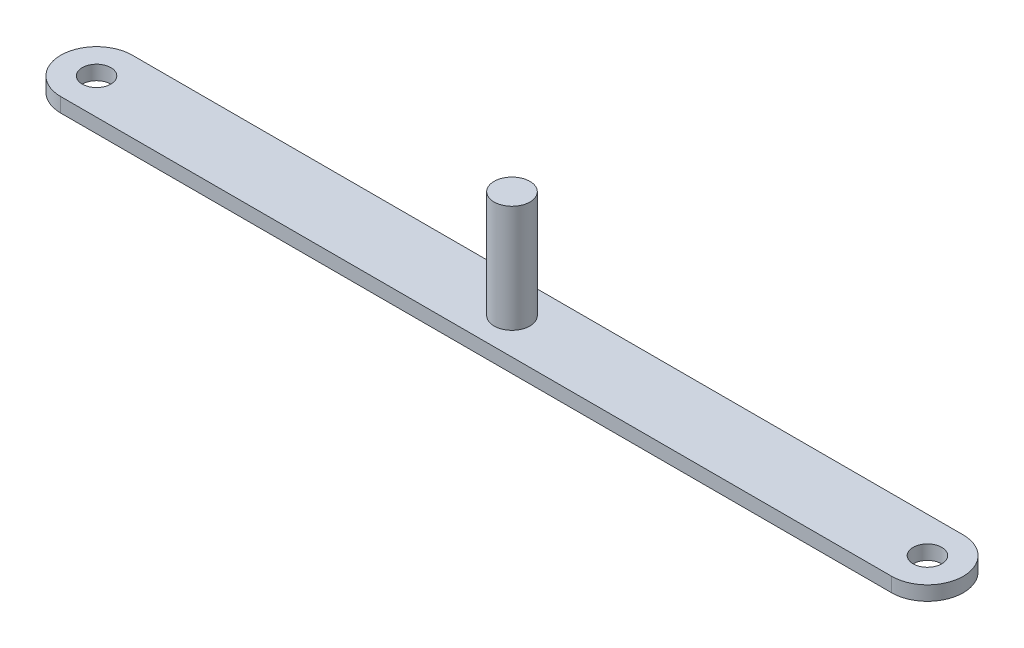
from build123d import *

# Parameters (mm, degrees)
SKETCH1_R           = 2
BOSS_EXTRUDE1_DEPTH = 2
SKETCH2_R           = 2.5
BOSS_EXTRUDE2_DEPTH = 15


with BuildPart() as part:
    # Sketch1 → Boss-Extrude1 (new body)
    with BuildSketch(Plane(origin=(0, 0, 0), x_dir=(1, 0, 0), z_dir=(0, 1, 0))):
        with BuildLine():
            Line((-58, 5), (58, 5))
            ThreePointArc((58, 5), (63, 0), (58, -5))
            Line((58, -5), (-58, -5))
            ThreePointArc((-58, -5), (-63, 0), (-58, 5))
        make_face()
        with Locations((-58, 0)):
            Circle(SKETCH1_R, mode=Mode.SUBTRACT)
        with Locations((58, 0)):
            Circle(SKETCH1_R, mode=Mode.SUBTRACT)
    extrude(amount=BOSS_EXTRUDE1_DEPTH)

    # Sketch2 → Boss-Extrude2 (add)
    with BuildSketch(Plane(origin=(0, 2, 0), x_dir=(1, 0, 0), z_dir=(0, 1, 0))):
        Circle(SKETCH2_R)
    extrude(amount=BOSS_EXTRUDE2_DEPTH)


solid = part.part
